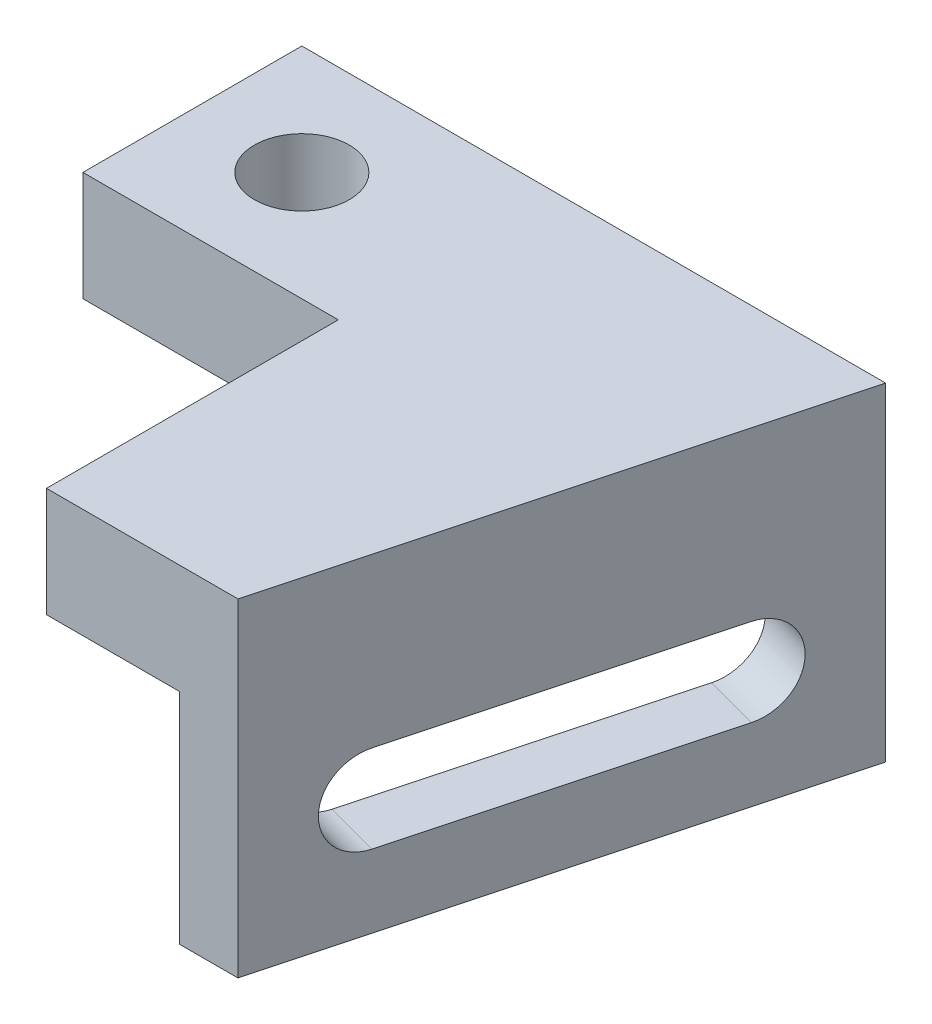
from build123d import *

# Parameters (mm, degrees)
SKETCH1_R           = 6.5
BOSS_EXTRUDE1_DEPTH = 15
BOSS_EXTRUDE3_DEPTH = 30
CUT_EXTRUDE1_DEPTH  = 10


with BuildPart() as part:
    # Sketch1 → Boss-Extrude1 (new body)
    with BuildSketch(Plane(origin=(0, 0, 0), x_dir=(1, 0, 0), z_dir=(0, 1, 0))):
        Polygon((45, 30), (26.24355653, -40), (0, -40), (0, 0), (-35, 0), (-35, 30), align=None)
        with Locations((-20, 15)):
            Circle(SKETCH1_R, mode=Mode.SUBTRACT)
    extrude(amount=BOSS_EXTRUDE1_DEPTH)

    # Sketch5 → Boss-Extrude3 (add)
    with BuildSketch(Plane.XZ):
        Polygon((18.24355653, 40), (37, -30), (45, -30), (26.24355653, 40), align=None)
    extrude(amount=BOSS_EXTRUDE3_DEPTH)

    # Sketch7 → Cut-Extrude1 (cut)
    with BuildSketch(Plane(origin=(34.485571585, 0, 9.240381057), x_dir=(0.258819045, 0, -0.965925826), z_dir=(0.965925826, 0, 0.258819045))):
        with BuildLine():
            Line((-16.84470081, -8), (25.624631818, -8))
            ThreePointArc((25.624631818, -8), (31.624631818, -14), (25.624631818, -20))
            Line((25.624631818, -20), (-16.84470081, -20))
            ThreePointArc((-16.84470081, -20), (-22.84470081, -14), (-16.84470081, -8))
        make_face()
    extrude(amount=-CUT_EXTRUDE1_DEPTH, mode=Mode.SUBTRACT)


solid = part.part
